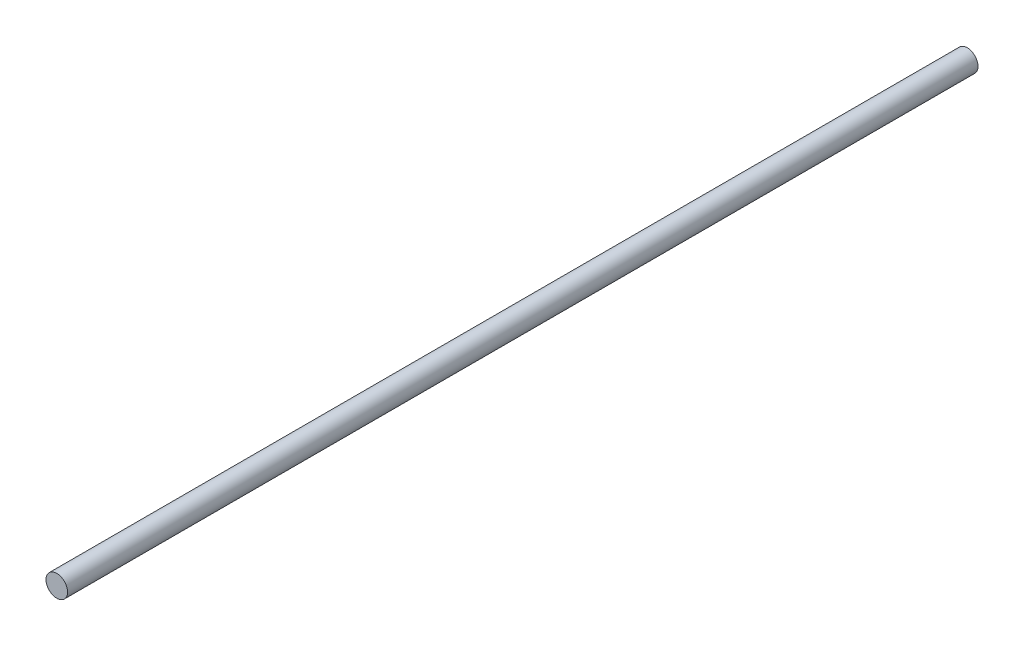
from build123d import *

# Parameters (mm, degrees)
SKETCH1_R           = 6.35
BOSS_EXTRUDE1_DEPTH = 268


with BuildPart() as part:
    # Sketch1 → Boss-Extrude1 (new body, symmetric)
    with BuildSketch(Plane.XY):
        Circle(SKETCH1_R)
    extrude(amount=BOSS_EXTRUDE1_DEPTH, both=True)


solid = part.part
